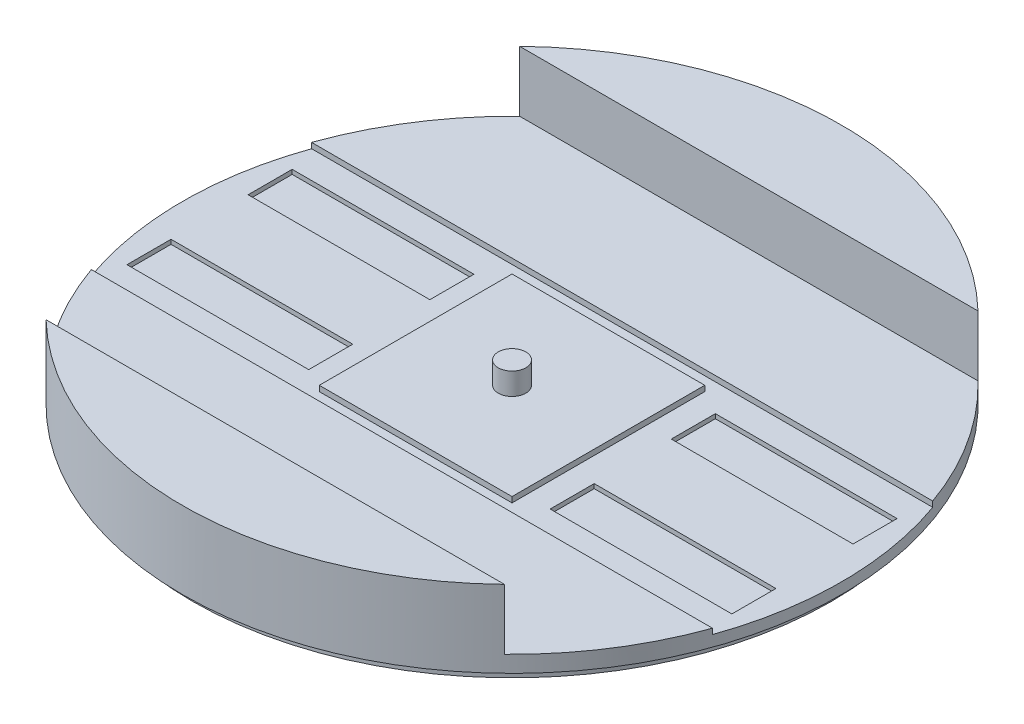
from build123d import *

# Parameters (mm, degrees)
SKETCH2_R           = 76
BOSS_EXTRUDE1_DEPTH = 17.78
CUT_EXTRUDE3_DEPTH  = 13.97
CUT_EXTRUDE5_DEPTH  = 1.27
SKETCH10_W          = 41.91
SKETCH10_H          = 10.16
CUT_EXTRUDE6_DEPTH  = 1.016
SKETCH11_W          = 44.45
SKETCH11_H          = 44.45
BOSS_EXTRUDE2_DEPTH = 1.27
SKETCH14_R          = 3.175
BOSS_EXTRUDE4_DEPTH = 5.08
SKETCH15_R          = 73.66
BOSS_EXTRUDE5_DEPTH = 2.54


with BuildPart() as part:
    # Sketch2 → Boss-Extrude1 (new body)
    with BuildSketch(Plane(origin=(0, 0, 0), x_dir=(1, 0, 0), z_dir=(0, 1, 0))):
        Circle(SKETCH2_R)
    extrude(amount=BOSS_EXTRUDE1_DEPTH)

    # Sketch6 → Cut-Extrude3 (cut)
    with BuildSketch(Plane(origin=(0, 17.78, 0), x_dir=(1, 0, 0), z_dir=(0, 1, 0))):
        with BuildLine():
            Line((-76, 54.61), (76, 54.61))
            ThreePointArc((76, 54.61), (130.61, 0), (76, -54.61))
            Line((76, -54.61), (-76, -54.61))
            ThreePointArc((-76, -54.61), (-130.61, 0), (-76, 54.61))
        make_face()
    extrude(amount=-CUT_EXTRUDE3_DEPTH, mode=Mode.SUBTRACT)

    # Sketch9 → Cut-Extrude5 (cut)
    with BuildSketch(Plane(origin=(0, 3.81, 0), x_dir=(1, 0, 0), z_dir=(0, 1, 0))):
        with BuildLine():
            Line((-76, 25.4), (-25.4, 25.4))
            Line((-25.4, 25.4), (25.4, 25.4))
            Line((25.4, 25.4), (76, 25.4))
            ThreePointArc((76, 25.4), (101.4, 0), (76, -25.4))
            Line((76, -25.4), (25.4, -25.4))
            Line((25.4, -25.4), (-25.4, -25.4))
            Line((-25.4, -25.4), (-76, -25.4))
            ThreePointArc((-76, -25.4), (-101.4, 0), (-76, 25.4))
        make_face()
    extrude(amount=-CUT_EXTRUDE5_DEPTH, mode=Mode.SUBTRACT)

    # Sketch10 → Cut-Extrude6 (cut)
    with BuildSketch(Plane(origin=(0, 2.54, 0), x_dir=(1, 0, 0), z_dir=(0, 1, 0))):
        with Locations((-48.79885899, 13.97)):
            Rectangle(SKETCH10_W, SKETCH10_H)
        with Locations((-48.79885899, -13.97)):
            Rectangle(SKETCH10_W, SKETCH10_H)
        with Locations((48.79885899, -13.97)):
            Rectangle(SKETCH10_W, SKETCH10_H)
        with Locations((48.79885899, 13.97)):
            Rectangle(SKETCH10_W, SKETCH10_H)
    extrude(amount=-CUT_EXTRUDE6_DEPTH, mode=Mode.SUBTRACT)

    # Sketch11 → Boss-Extrude2 (add)
    with BuildSketch(Plane(origin=(0, 2.54, 0), x_dir=(1, 0, 0), z_dir=(0, 1, 0))):
        Rectangle(SKETCH11_W, SKETCH11_H)
    extrude(amount=BOSS_EXTRUDE2_DEPTH)

    # Sketch14 → Boss-Extrude4 (add)
    with BuildSketch(Plane(origin=(0, 3.81, 0), x_dir=(1, 0, 0), z_dir=(0, 1, 0))):
        Circle(SKETCH14_R)
    extrude(amount=BOSS_EXTRUDE4_DEPTH)

    # Sketch15 → Boss-Extrude5 (add)
    with BuildSketch(Plane.XZ):
        Circle(SKETCH15_R)
    extrude(amount=BOSS_EXTRUDE5_DEPTH)


solid = part.part
